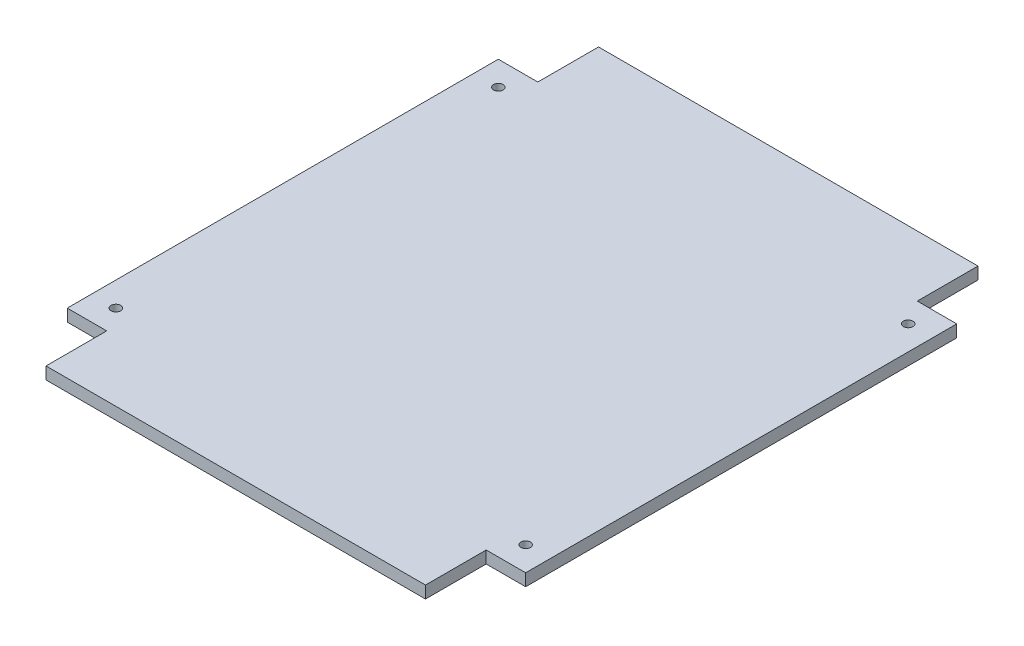
from build123d import *

# Parameters (mm, degrees)
BOSS_EXTRUDE1_DEPTH = 2.54
SKETCH5_R           = 0.99949
CUT_EXTRUDE2_DEPTH  = 3.54


with BuildPart() as part:
    # Sketch1 → Boss-Extrude1 (new body)
    with BuildSketch(Plane(origin=(0, 0, 0), x_dir=(1, 0, 0), z_dir=(0, 1, 0))):
        Polygon((-47.9425, 45.085), (-39.6875, 45.085), (-39.6875, 57.785), (39.6875, 57.785), (39.6875, 45.085), (47.9425, 45.085), (47.9425, -45.085), (39.6875, -45.085), (39.6875, -57.785), (-39.6875, -57.785), (-39.6875, -45.085), (-47.9425, -45.085), align=None)
    extrude(amount=BOSS_EXTRUDE1_DEPTH)

    # Sketch5 → Cut-Extrude2 (cut, through all)
    with BuildSketch(Plane(origin=(0, 2.54, 0), x_dir=(1, 0, 0), z_dir=(0, 1, 0))):
        with Locations((42.8625, -40.005)):
            Circle(SKETCH5_R)
        with Locations((42.8625, 40.005)):
            Circle(SKETCH5_R)
        with Locations((-42.8625, -40.005)):
            Circle(SKETCH5_R)
        with Locations((-42.8625, 40.005)):
            Circle(SKETCH5_R)
    extrude(amount=-CUT_EXTRUDE2_DEPTH, mode=Mode.SUBTRACT)


solid = part.part
